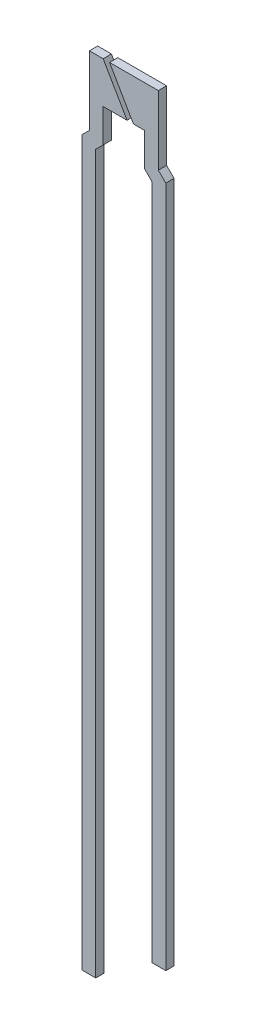
from build123d import *

# Parameters (mm, degrees)
BOSS_EXTRUDE1_DEPTH   = 0.15
BOSS_EXTRUDE1_2_DEPTH = 0.15


with BuildPart() as part:
    # Sketch1 → Boss-Extrude1 (new, symmetric)
    with BuildSketch(Plane.XY):
        Polygon((1.02, -0.977106781), (1.02, -25.5), (1.52, -25.5), (1.52, -0.77), (1.25, -0.5), (1.25, 0.5), (1.25, 2), (-0.519059892, 2), (0.346965511, 0.5), (0.75, 0.5), (0.75, -0.707106781), align=None)
    extrude(amount=BOSS_EXTRUDE1_DEPTH, both=True)


with BuildPart() as body_2:
    # Sketch1 → Boss-Extrude1 2 (new, symmetric)
    with BuildSketch(Plane.XY):
        Polygon((-1.52, -0.77), (-1.25, -0.5), (-1.25, 0.5), (-1.25, 2), (-0.75, 2), (0.116025404, 0.5), (-0.75, 0.5), (-0.75, -0.707106781), (-1.02, -0.977106781), (-1.02, -27), (-1.52, -27), align=None)
    extrude(amount=BOSS_EXTRUDE1_2_DEPTH, both=True)


solid = Compound([part.part, body_2.part])
